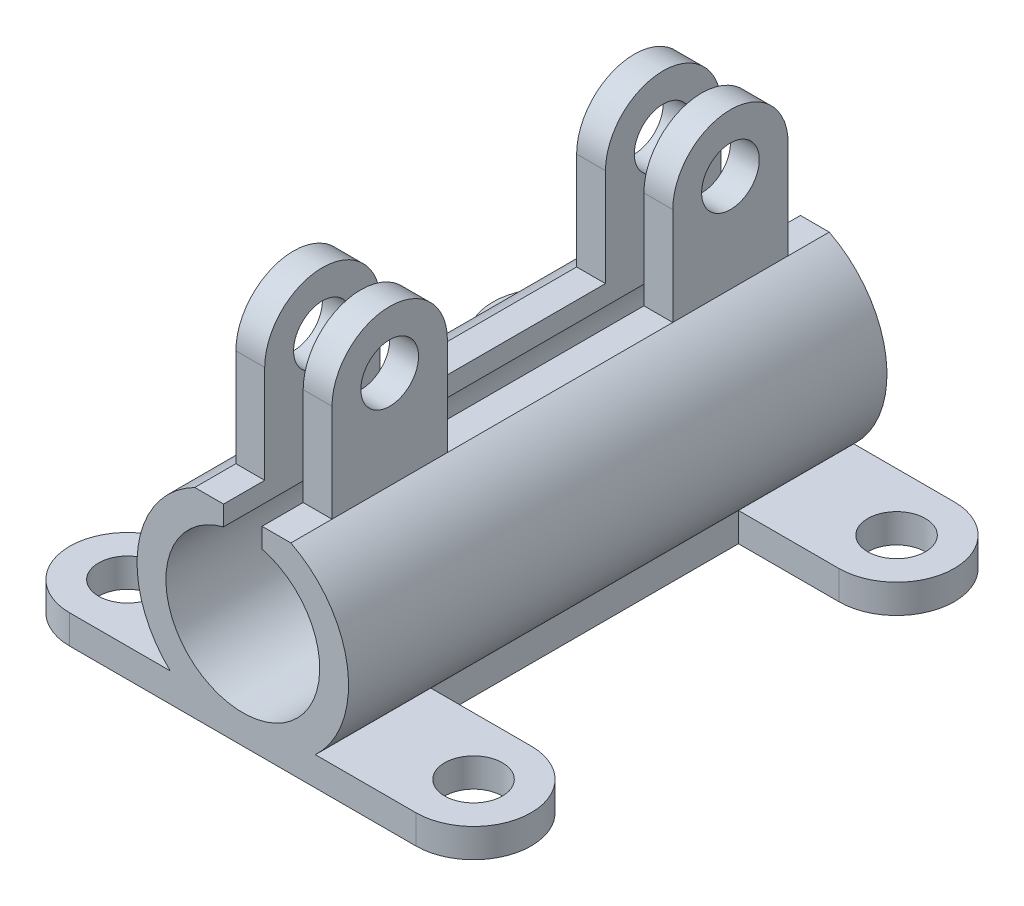
from build123d import *

# Parameters (mm, degrees)
BOSS_EXTRUDE1_DEPTH       = 280
SKETCH4_R                 = 15
BOSS_EXTRUDE2_DEPTH       = 15
CUT_EXTRUDE1_DEPTH        = 15
CUT_EXTRUDE2_DEPTH        = 15
SKETCH9_R                 = 15
CUT_EXTRUDE3_DEPTH        = 15
LPATTERN1_COUNT           = 2
LPATTERN1_PITCH           = 180
LPATTERN2_COUNT           = 2
LPATTERN2_PITCH           = 220
LPATTERN2_COPY_1_SKETCH_R = 15
LPATTERN2_COPY_1_DEPTH    = 15


with BuildPart() as part:
    # Sketch1 → Boss-Extrude1 (new body)
    with BuildSketch(Plane.XY):
        with BuildLine():
            Line((-120, 0), (120, 0))
            Line((120, 0), (120, 15))
            Line((120, 15), (37.749172176, 15))
            ThreePointArc((37.749172176, 15), (54.444104817, 62.799964787), (25, 103.989794856))
            Line((25, 103.989794856), (10, 103.989794856))
            Line((10, 103.989794856), (10, 93.729833462))
            ThreePointArc((10, 93.729833462), (0, 15), (-10, 93.729833462))
            Line((-10, 93.729833462), (-10, 103.989794856))
            Line((-10, 103.989794856), (-25, 103.989794856))
            ThreePointArc((-25, 103.989794856), (-54.444104817, 62.799964787), (-37.749172176, 15))
            Line((-37.749172176, 15), (-120, 15))
            Line((-120, 15), (-120, 0))
        make_face()
    extrude(amount=BOSS_EXTRUDE1_DEPTH)

    # Sketch4 → Boss-Extrude2 (add)
    with BuildSketch(Plane(origin=(-10, 0, 0), x_dir=(0, 0, -1), z_dir=(1, 0, 0))):
        with BuildLine():
            Line((-258.604852185, 154.832655732), (-258.604852185, 103.989794856))
            Line((-258.604852185, 103.989794856), (-198.604852185, 103.989794856))
            Line((-198.604852185, 103.989794856), (-198.604852185, 154.832655732))
            ThreePointArc((-198.604852185, 154.832655732), (-228.604852185, 184.832655732), (-258.604852185, 154.832655732))
        make_face()
        with Locations((-228.604852185, 154.832655732)):
            Circle(SKETCH4_R, mode=Mode.SUBTRACT)
        with BuildLine():
            Line((-81.395147815, 103.989794856), (-21.395147815, 103.989794856))
            Line((-21.395147815, 103.989794856), (-21.395147815, 154.832655732))
            ThreePointArc((-21.395147815, 154.832655732), (-51.395147815, 184.832655732), (-81.395147815, 154.832655732))
            Line((-81.395147815, 154.832655732), (-81.395147815, 103.989794856))
        make_face()
        with Locations((-51.395147815, 154.832655732)):
            Circle(SKETCH4_R, mode=Mode.SUBTRACT)
    boss_extrude2 = extrude(amount=-BOSS_EXTRUDE2_DEPTH)

    # Mirror1: Boss-Extrude2 across plane
    add(boss_extrude2.mirror(Plane(origin=(0, 0, 0), x_dir=(0, 0, 1), z_dir=(1, 0, 0))))

    # Sketch5 → Cut-Extrude1 (cut)
    with BuildSketch(Plane(origin=(0, 15, 0), x_dir=(1, 0, 0), z_dir=(0, 1, 0))):
        with BuildLine():
            Line((120, -250), (120, -30.000000185))
            ThreePointArc((120, -30.000000185), (111.21320337, -51.213203501), (90, -60))
            Line((90, -60), (37.749172176, -60))
            Line((37.749172176, -60), (37.749172176, -220))
            Line((37.749172176, -220), (90, -220))
            ThreePointArc((90, -220), (111.213203436, -228.786796564), (120, -250))
        make_face()
        with BuildLine():
            Line((120, 0), (90, 0))
            ThreePointArc((90, 0), (111.213203501, -8.78679663), (120, -30.000000185))
            Line((120, -30.000000185), (120, 0))
        make_face()
        with BuildLine():
            Line((120, -280), (120, -250))
            ThreePointArc((120, -250), (111.213203436, -271.213203436), (90, -280))
            Line((90, -280), (120, -280))
        make_face()
    extrude(amount=-CUT_EXTRUDE1_DEPTH, mode=Mode.SUBTRACT)

    # Sketch7 → Cut-Extrude2 (cut)
    with BuildSketch(Plane(origin=(0, 15, 0), x_dir=(1, 0, 0), z_dir=(0, 1, 0))):
        with BuildLine():
            Line((-37.749172176, -220), (-37.749172176, -60))
            Line((-37.749172176, -60), (-90, -60))
            ThreePointArc((-90, -60), (-111.213203468, -51.213203403), (-120, -29.999999908))
            Line((-120, -29.999999908), (-120, -250))
            ThreePointArc((-120, -250), (-111.213203436, -228.786796564), (-90, -220))
            Line((-90, -220), (-37.749172176, -220))
        make_face()
        with BuildLine():
            ThreePointArc((-120, -29.999999908), (-111.213203403, -8.786796532), (-90, 0))
            Line((-90, 0), (-120, 0))
            Line((-120, 0), (-120, -29.999999908))
        make_face()
        with BuildLine():
            ThreePointArc((-90, -280), (-111.213203436, -271.213203436), (-120, -250))
            Line((-120, -250), (-120, -280))
            Line((-120, -280), (-90, -280))
        make_face()
    extrude(amount=-CUT_EXTRUDE2_DEPTH, mode=Mode.SUBTRACT)

    # Sketch9 → Cut-Extrude3 (cut)
    with BuildSketch(Plane(origin=(0, 15, 0), x_dir=(1, 0, 0), z_dir=(0, 1, 0))):
        with Locations((90, -30)):
            Circle(SKETCH9_R)
    cut_extrude3 = extrude(amount=-CUT_EXTRUDE3_DEPTH, mode=Mode.SUBTRACT)

    # LPattern1: Cut-Extrude3 ×2
    with Locations(*[(-i * LPATTERN1_PITCH, 0, 0) for i in range(1, LPATTERN1_COUNT)]):
        add(cut_extrude3, mode=Mode.SUBTRACT)

    # LPattern2: Cut-Extrude3 ×2
    with Locations(*[(0, 0, i * LPATTERN2_PITCH) for i in range(1, LPATTERN2_COUNT)]):
        add(cut_extrude3, mode=Mode.SUBTRACT)

    # LPattern2 copy 1 sketch → LPattern2 copy 1 (cut)
    with BuildSketch(Plane(origin=(-180, 15, 220), x_dir=(1, 0, 0), z_dir=(0, 1, 0))):
        with Locations((90, -30)):
            Circle(LPATTERN2_COPY_1_SKETCH_R)
    extrude(amount=-LPATTERN2_COPY_1_DEPTH, mode=Mode.SUBTRACT)


solid = part.part
